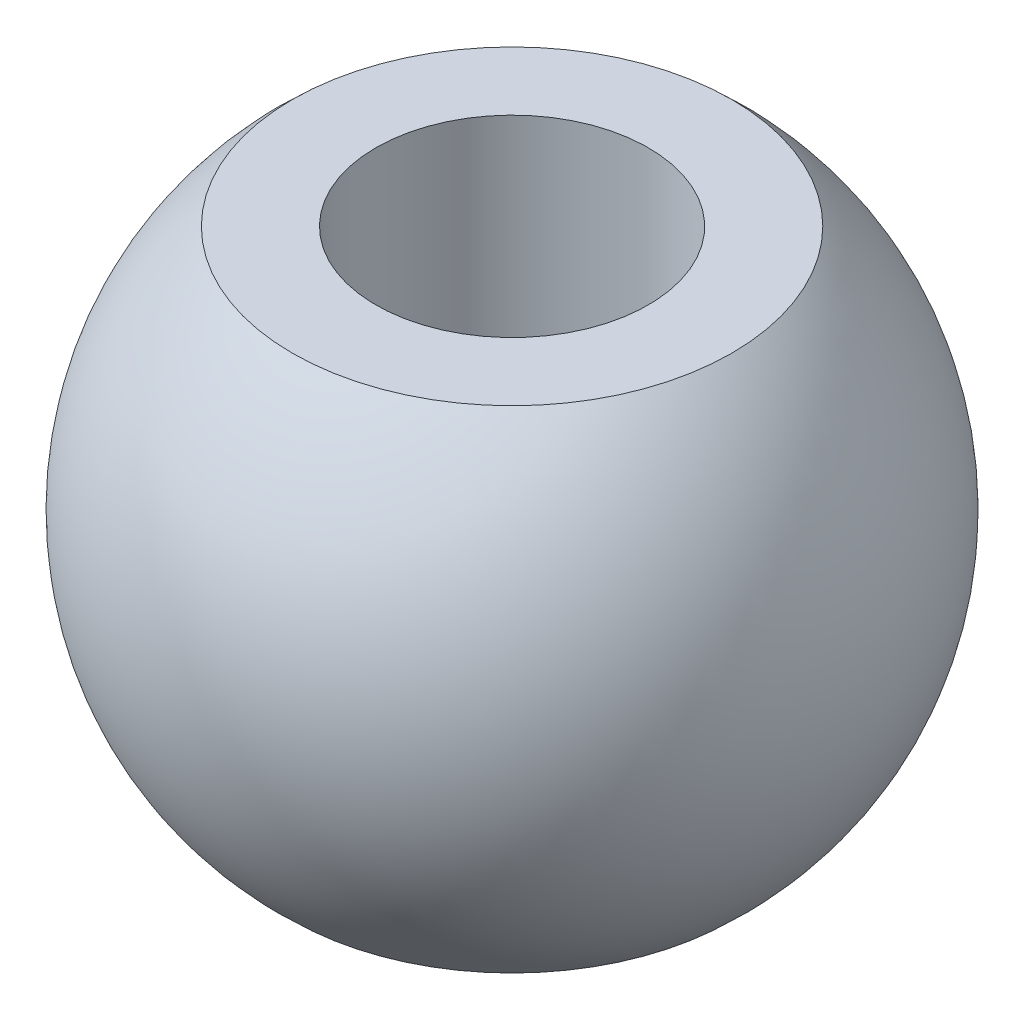
from build123d import *

# Parameters (mm, degrees)
SKETCH3_R          = 3.1
CUT_EXTRUDE1_DEPTH = 12.180339887


with BuildPart() as part:
    # Sketch2 → Revolve1 (revolve)
    with BuildSketch(Plane.XY):
        with BuildLine():
            Line((0, 5.590169944), (0, -5.590169944))
            Line((0, -5.590169944), (-5, -5.590169944))
            ThreePointArc((-5, -5.590169944), (-7.5, 0), (-5, 5.590169944))
            Line((-5, 5.590169944), (0, 5.590169944))
        make_face()
    revolve(axis=Axis((0, 5.590169944, 0), (0, -1, 0)))

    # Sketch3 → Cut-Extrude1 (cut, through all)
    with BuildSketch(Plane(origin=(0, 5.590169944, 0), x_dir=(1, 0, 0), z_dir=(0, 1, 0))):
        Circle(SKETCH3_R)
    extrude(amount=-CUT_EXTRUDE1_DEPTH, mode=Mode.SUBTRACT)


solid = part.part
